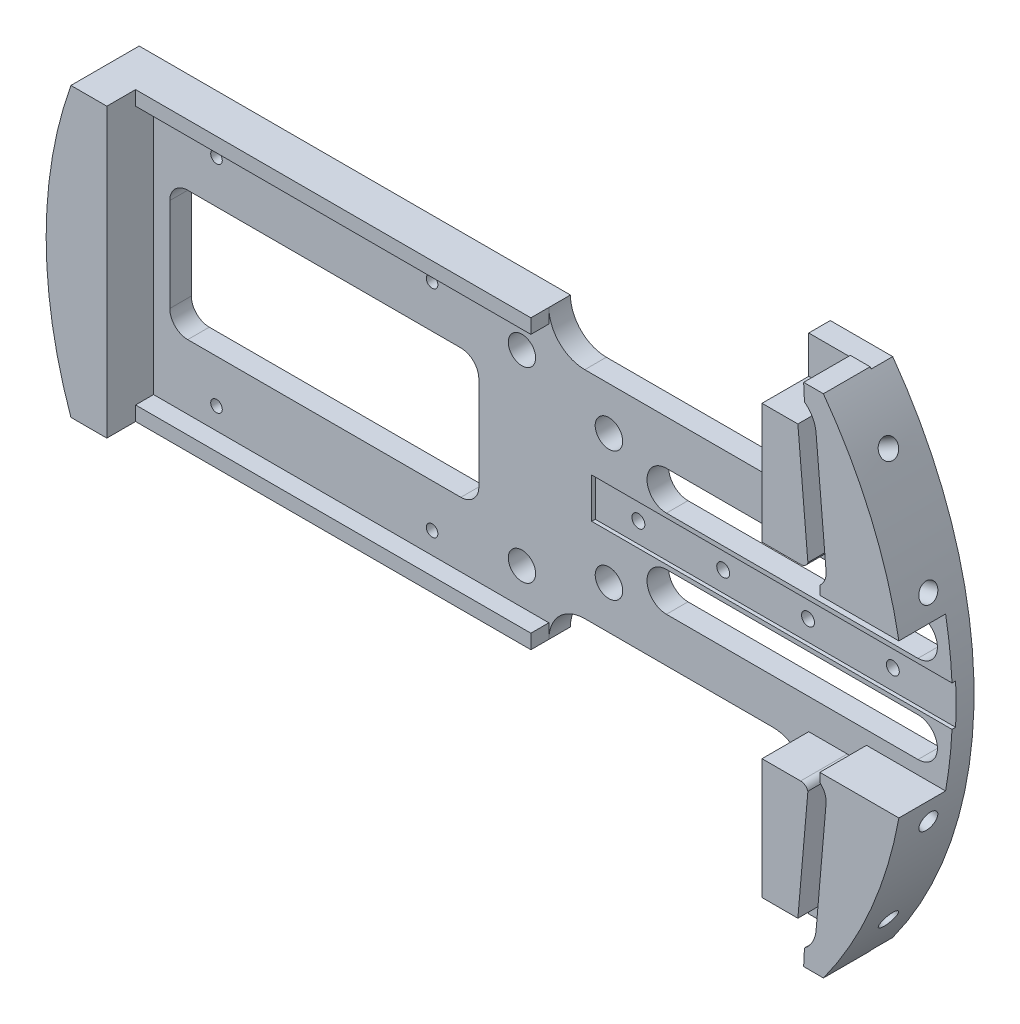
from build123d import *

# Parameters (mm, degrees)
BOSS_EXTRUDE1_DEPTH     = 3.81
BOSS_EXTRUDE2_DEPTH     = 8.255
SKETCH3_W               = 64.77
SKETCH3_H               = 7.1
CUT_EXTRUDE1_DEPTH      = 0.635
CUT_EXTRUDE4_DEPTH      = 4.81
CUT_EXTRUDE5_DEPTH      = 4.81
SKETCH12_R              = 2.4257
CUT_EXTRUDE6_DEPTH      = 4.81
SKETCH4_R               = 1.143
CUT_EXTRUDE2_DEPTH      = 11.43
SKETCH17_R              = 2.413
CUT_EXTRUDE9_DEPTH      = 4.81
BOSS_EXTRUDE5_DEPTH     = 8.255
SKETCH20_W              = 69.85
SKETCH20_H              = 3.175
BOSS_EXTRUDE6_DEPTH     = 2.54
SKETCH21_R              = 1.02235
CUT_EXTRUDE10_DEPTH     = 13.065
SKETCH24_R              = 1.6383
CUT_EXTRUDE11_DEPTH     = 8.128
CIRPATTERN1_COUNT       = 2
CIRPATTERN1_ANGLE       = 15
MIRROR2_COPY_1_SKETCH_R = 1.6383
MIRROR2_COPY_1_DEPTH    = 8.128


with BuildPart() as part:
    # Sketch1 → Boss-Extrude1 (new body)
    with BuildSketch(Plane.XY):
        with BuildLine():
            Line((10.977415053, 19.05), (44.196, 19.05))
            ThreePointArc((44.196, 19.05), (48.686128061, 20.909871939), (50.546, 25.4))
            Line((50.546, 25.4), (50.546, 44.45))
            Line((50.546, 44.45), (61.579155694, 44.45))
            ThreePointArc((61.579155694, 44.45), (75.946, 0), (61.579155694, -44.45))
            Line((61.579155694, -44.45), (50.546, -44.45))
            Line((50.546, -44.45), (50.546, -25.4))
            ThreePointArc((50.546, -25.4), (48.686128061, -20.909871939), (44.196, -19.05))
            Line((44.196, -19.05), (10.977415053, -19.05))
            ThreePointArc((10.977415053, -19.05), (6.487286992, -20.909871939), (4.627415053, -25.4))
            Line((4.627415053, -25.4), (-71.572584947, -25.4))
            ThreePointArc((-71.572584947, -25.4), (-75.946, 0), (-71.572584947, 25.4))
            Line((-71.572584947, 25.4), (4.627415053, 25.4))
            ThreePointArc((4.627415053, 25.4), (6.487286992, 20.909871939), (10.977415053, 19.05))
        make_face()
    extrude(amount=BOSS_EXTRUDE1_DEPTH)

    # Sketch2 → Boss-Extrude2 (add)
    with BuildSketch(Plane.XY.offset(3.81)):
        with BuildLine():
            Line((61.865268471, 17.78), (60.095110466, 38.1))
            ThreePointArc((60.095110466, 38.1), (59.464196764, 40.158289632), (58.047089349, 41.778911391))
            Line((58.047089349, 41.778911391), (57.900800643, 44.704))
            Line((57.900800643, 44.704), (61.395010384, 44.704))
            ThreePointArc((61.395010384, 44.704), (69.822038137, 29.877715884), (74.728381149, 13.544887112))
            Line((74.728381149, 13.544887112), (60.759450402, 13.544887112))
            Line((60.759450402, 13.544887112), (60.759450402, 15.094127876))
            ThreePointArc((60.759450402, 15.094127876), (61.639191639, 16.302501703), (61.865268471, 17.78))
        make_face()
        with BuildLine():
            Line((58.651639318, 17.500047669), (56.881481313, 37.820047669))
            Line((56.881481313, 37.820047669), (50.546, 37.820047669))
            Line((50.546, 37.820047669), (50.546, 16.566735288))
            Line((50.546, 16.566735288), (57.366094516, 16.566735288))
            ThreePointArc((57.366094516, 16.566735288), (58.160401987, 16.824667019), (58.651639318, 17.500047669))
        make_face()
        with BuildLine():
            Line((60.759450402, -13.544887112), (74.728381149, -13.544887112))
            ThreePointArc((74.728381149, -13.544887112), (69.822038137, -29.877715884), (61.395010384, -44.704))
            Line((61.395010384, -44.704), (57.900800643, -44.704))
            Line((57.900800643, -44.704), (58.047089349, -41.778911391))
            ThreePointArc((58.047089349, -41.778911391), (59.464196764, -40.158289632), (60.095110466, -38.1))
            Line((60.095110466, -38.1), (61.865268471, -17.78))
            ThreePointArc((61.865268471, -17.78), (61.639191639, -16.302501703), (60.759450402, -15.094127876))
            Line((60.759450402, -15.094127876), (60.759450402, -13.544887112))
        make_face()
        with BuildLine():
            Line((50.546, -16.566735288), (57.366094516, -16.566735288))
            ThreePointArc((57.366094516, -16.566735288), (58.160401987, -16.824667019), (58.651639318, -17.500047669))
            Line((58.651639318, -17.500047669), (56.881481313, -37.820047669))
            Line((56.881481313, -37.820047669), (50.546, -37.820047669))
            Line((50.546, -37.820047669), (50.546, -16.566735288))
        make_face()
    extrude(amount=BOSS_EXTRUDE2_DEPTH)

    # Sketch3 → Cut-Extrude1 (cut)
    with BuildSketch(Plane.XY.offset(3.81)):
        with Locations((44.577, 0)):
            Rectangle(SKETCH3_W, SKETCH3_H)
    extrude(amount=-CUT_EXTRUDE1_DEPTH, mode=Mode.SUBTRACT)

    # Sketch9 → Cut-Extrude4 (cut, through all)
    with BuildSketch(Plane.XY.offset(3.81)):
        with BuildLine():
            Line((69.85, 11.17), (25.4, 11.17))
            ThreePointArc((25.4, 11.17), (21.971, 7.741), (25.4, 4.312))
            Line((25.4, 4.312), (69.85, 4.312))
            ThreePointArc((69.85, 4.312), (73.279, 7.741), (69.85, 11.17))
        make_face()
        with BuildLine():
            Line((69.85, -4.312), (25.4, -4.312))
            ThreePointArc((25.4, -4.312), (21.971, -7.741), (25.4, -11.17))
            Line((25.4, -11.17), (69.85, -11.17))
            ThreePointArc((69.85, -11.17), (73.279, -7.741), (69.85, -4.312))
        make_face()
    extrude(amount=-CUT_EXTRUDE4_DEPTH, mode=Mode.SUBTRACT)

    # Sketch10 → Cut-Extrude5 (cut, through all)
    with BuildSketch(Plane.XY.offset(3.81)):
        with BuildLine():
            Line((-10.922, 11.43), (-59.182, 11.43))
            ThreePointArc((-59.182, 11.43), (-61.42706403, 10.50006403), (-62.357, 8.255))
            Line((-62.357, 8.255), (-62.357, -8.255))
            ThreePointArc((-62.357, -8.255), (-61.42706403, -10.50006403), (-59.182, -11.43))
            Line((-59.182, -11.43), (-10.922, -11.43))
            ThreePointArc((-10.922, -11.43), (-8.67693597, -10.50006403), (-7.747, -8.255))
            Line((-7.747, -8.255), (-7.747, 8.255))
            ThreePointArc((-7.747, 8.255), (-8.67693597, 10.50006403), (-10.922, 11.43))
        make_face()
    extrude(amount=-CUT_EXTRUDE5_DEPTH, mode=Mode.SUBTRACT)

    # Sketch12 → Cut-Extrude6 (cut, through all)
    with BuildSketch(Plane.XY.offset(3.81)):
        with Locations((15.24, 11.43)):
            Circle(SKETCH12_R)
        with Locations((15.24, -11.43)):
            Circle(SKETCH12_R)
    extrude(amount=-CUT_EXTRUDE6_DEPTH, mode=Mode.SUBTRACT)

    # Sketch4 → Cut-Extrude2 (cut)
    with BuildSketch(Plane.XY.offset(3.175)):
        with Locations((19.812, 0)):
            Circle(SKETCH4_R)
        with Locations((34.798, 0)):
            Circle(SKETCH4_R)
        with Locations((49.784, 0)):
            Circle(SKETCH4_R)
        with Locations((64.77, 0)):
            Circle(SKETCH4_R)
    extrude(amount=-CUT_EXTRUDE2_DEPTH, mode=Mode.SUBTRACT)

    # Sketch17 → Cut-Extrude9 (cut, through all)
    with BuildSketch(Plane.XY.offset(3.81)):
        with Locations((-0.127, 16.51)):
            Circle(SKETCH17_R)
        with Locations((-0.127, -16.51)):
            Circle(SKETCH17_R)
    extrude(amount=-CUT_EXTRUDE9_DEPTH, mode=Mode.SUBTRACT)

    # Sketch19 → Boss-Extrude5 (add)
    with BuildSketch(Plane.XY.offset(3.81)):
        with BuildLine():
            Line((-71.572584947, -25.4), (-65.222584947, -25.4))
            Line((-65.222584947, -25.4), (-65.222584947, 25.4))
            Line((-65.222584947, 25.4), (-71.572584947, 25.4))
            ThreePointArc((-71.572584947, 25.4), (-75.946, 0), (-71.572584947, -25.4))
        make_face()
    extrude(amount=BOSS_EXTRUDE5_DEPTH)

    # Sketch20 → Boss-Extrude6 (add)
    with BuildSketch(Plane.XZ.offset(25.4)):
        with Locations((-30.297584947, 5.3975)):
            Rectangle(SKETCH20_W, SKETCH20_H)
    boss_extrude6 = extrude(amount=-BOSS_EXTRUDE6_DEPTH)

    # Mirror1: Boss-Extrude6 across plane
    add(boss_extrude6.mirror(Plane.ZX))

    # Sketch21 → Cut-Extrude10 (cut, through all)
    with BuildSketch(Plane(origin=(0, 0, 0), x_dir=(-1, 0, 0), z_dir=(0, 0, -1))):
        with Locations((54.102, 19.05)):
            Circle(SKETCH21_R)
        with Locations((16.002, 19.05)):
            Circle(SKETCH21_R)
        with Locations((16.002, -19.05)):
            Circle(SKETCH21_R)
        with Locations((54.102, -19.05)):
            Circle(SKETCH21_R)
    extrude(amount=-CUT_EXTRUDE10_DEPTH, mode=Mode.SUBTRACT)

    # Sketch24 → Cut-Extrude11 (cut)
    with BuildSketch(Plane(origin=(65.771165316, 37.973, 0), x_dir=(0, 0, -1), z_dir=(0.866025404, 0.5, 0))):
        with Locations((-6.0325, -2.224428615)):
            Circle(SKETCH24_R)
    cut_extrude11 = extrude(amount=-CUT_EXTRUDE11_DEPTH, mode=Mode.SUBTRACT)

    # CirPattern1: Cut-Extrude11 ×2 about axis
    cirpattern1_axis = Axis((0, 0, 3.81), (0, 0, -1))
    for i in range(1, CIRPATTERN1_COUNT):
        add(cut_extrude11.rotate(cirpattern1_axis, i * CIRPATTERN1_ANGLE / (CIRPATTERN1_COUNT - 1)), mode=Mode.SUBTRACT)

    # Mirror2: Cut-Extrude11 across plane
    add(cut_extrude11.mirror(Plane.ZX), mode=Mode.SUBTRACT)

    # Mirror2 copy 1 sketch → Mirror2 copy 1 (cut)
    with BuildSketch(Plane(origin=(73.358202803, -19.656271199, 0), x_dir=(0, 0, -1), z_dir=(0.965925826, -0.258819045, 0))):
        with Locations((-6.0325, 2.224428615)):
            Circle(MIRROR2_COPY_1_SKETCH_R)
    extrude(amount=-MIRROR2_COPY_1_DEPTH, mode=Mode.SUBTRACT)


solid = part.part
